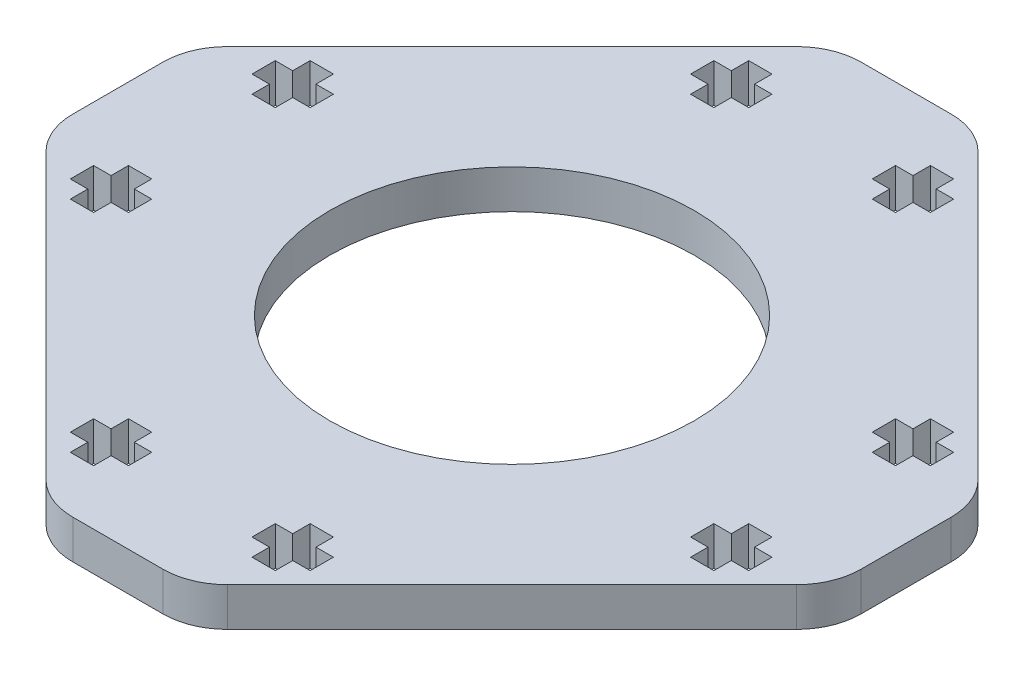
from build123d import *

# Parameters (mm, degrees)
SKETCH1_R           = 14.1
BOSS_EXTRUDE1_DEPTH = 3
CUT_EXTRUDE1_DEPTH  = 4


with BuildPart() as part:
    # Sketch1 → Boss-Extrude1 (new body)
    with BuildSketch(Plane(origin=(0, 0, 0), x_dir=(1, 0, 0), z_dir=(0, 1, 0))):
        with BuildLine():
            Line((3.491378029, 30.5), (-3.491378029, 30.5))
            ThreePointArc((-3.491378029, 30.5), (-5.40479519, 30.119397663), (-7.026911935, 29.035533906))
            Line((-7.026911935, 29.035533906), (-29.035533906, 7.026911935))
            ThreePointArc((-29.035533906, 7.026911935), (-30.119397663, 5.40479519), (-30.5, 3.491378029))
            Line((-30.5, 3.491378029), (-30.5, -3.491378029))
            ThreePointArc((-30.5, -3.491378029), (-30.119397663, -5.40479519), (-29.035533906, -7.026911935))
            Line((-29.035533906, -7.026911935), (-7.026911935, -29.035533906))
            ThreePointArc((-7.026911935, -29.035533906), (-5.40479519, -30.119397663), (-3.491378029, -30.5))
            Line((-3.491378029, -30.5), (3.491378029, -30.5))
            ThreePointArc((3.491378029, -30.5), (5.40479519, -30.119397663), (7.026911935, -29.035533906))
            Line((7.026911935, -29.035533906), (29.035533906, -7.026911935))
            ThreePointArc((29.035533906, -7.026911935), (30.119397662, -5.404795191), (30.5, -3.491378029))
            Line((30.5, -3.491378029), (30.5, 3.491378029))
            ThreePointArc((30.5, 3.491378029), (30.119397662, 5.40479519), (29.035533906, 7.026911934))
            Line((29.035533906, 7.026911934), (7.026911934, 29.035533906))
            ThreePointArc((7.026911934, 29.035533906), (5.40479519, 30.119397662), (3.491378029, 30.5))
        make_face()
        Circle(SKETCH1_R, mode=Mode.SUBTRACT)
    extrude(amount=BOSS_EXTRUDE1_DEPTH)

    # Sketch2 → Cut-Extrude1 (cut, through all)
    with BuildSketch(Plane(origin=(0, 3, 0), x_dir=(1, 0, 0), z_dir=(0, 1, 0))):
        Polygon((-26.25, 7.929437252), (-26.25, 6.129437252), (-24.9, 6.129437252), (-24.9, 4.779437252), (-23.1, 4.779437252), (-23.1, 6.129437252), (-21.75, 6.129437252), (-21.75, 7.929437252), (-23.1, 7.929437252), (-23.1, 9.279437252), (-24.9, 9.279437252), (-24.9, 7.929437252), align=None)
        Polygon((-23.1, -4.779437252), (-24.9, -4.779437252), (-24.9, -6.129437252), (-26.25, -6.129437252), (-26.25, -7.929437252), (-24.9, -7.929437252), (-24.9, -9.279437252), (-23.1, -9.279437252), (-23.1, -7.929437252), (-21.75, -7.929437252), (-21.75, -6.129437252), (-23.1, -6.129437252), align=None)
        Polygon((7.929437252, 23.1), (9.279437252, 23.1), (9.279437252, 24.9), (7.929437252, 24.9), (7.929437252, 26.25), (6.129437252, 26.25), (6.129437252, 24.9), (4.779437252, 24.9), (4.779437252, 23.1), (6.129437252, 23.1), (6.129437252, 21.75), (7.929437252, 21.75), align=None)
        Polygon((26.25, -7.929437252), (26.25, -6.129437252), (24.9, -6.129437252), (24.9, -4.779437252), (23.1, -4.779437252), (23.1, -6.129437252), (21.75, -6.129437252), (21.75, -7.929437252), (23.1, -7.929437252), (23.1, -9.279437252), (24.9, -9.279437252), (24.9, -7.929437252), align=None)
        Polygon((-4.779437252, 24.9), (-6.129437252, 24.9), (-6.129437252, 26.25), (-7.929437252, 26.25), (-7.929437252, 24.9), (-9.279437252, 24.9), (-9.279437252, 23.1), (-7.929437252, 23.1), (-7.929437252, 21.75), (-6.129437252, 21.75), (-6.129437252, 23.1), (-4.779437252, 23.1), align=None)
        Polygon((26.25, 7.929437252), (24.9, 7.929437252), (24.9, 9.279437252), (23.1, 9.279437252), (23.1, 7.929437252), (21.75, 7.929437252), (21.75, 6.129437252), (23.1, 6.129437252), (23.1, 4.779437252), (24.9, 4.779437252), (24.9, 6.129437252), (26.25, 6.129437252), align=None)
        Polygon((-6.129437252, -26.25), (-6.129437252, -24.9), (-4.779437252, -24.9), (-4.779437252, -23.1), (-6.129437252, -23.1), (-6.129437252, -21.75), (-7.929437252, -21.75), (-7.929437252, -23.1), (-9.279437252, -23.1), (-9.279437252, -24.9), (-7.929437252, -24.9), (-7.929437252, -26.25), align=None)
        Polygon((7.929437252, -26.25), (7.929437252, -24.9), (9.279437252, -24.9), (9.279437252, -23.1), (7.929437252, -23.1), (7.929437252, -21.75), (6.129437252, -21.75), (6.129437252, -23.1), (4.779437252, -23.1), (4.779437252, -24.9), (6.129437252, -24.9), (6.129437252, -26.25), align=None)
    extrude(amount=-CUT_EXTRUDE1_DEPTH, mode=Mode.SUBTRACT)


solid = part.part
